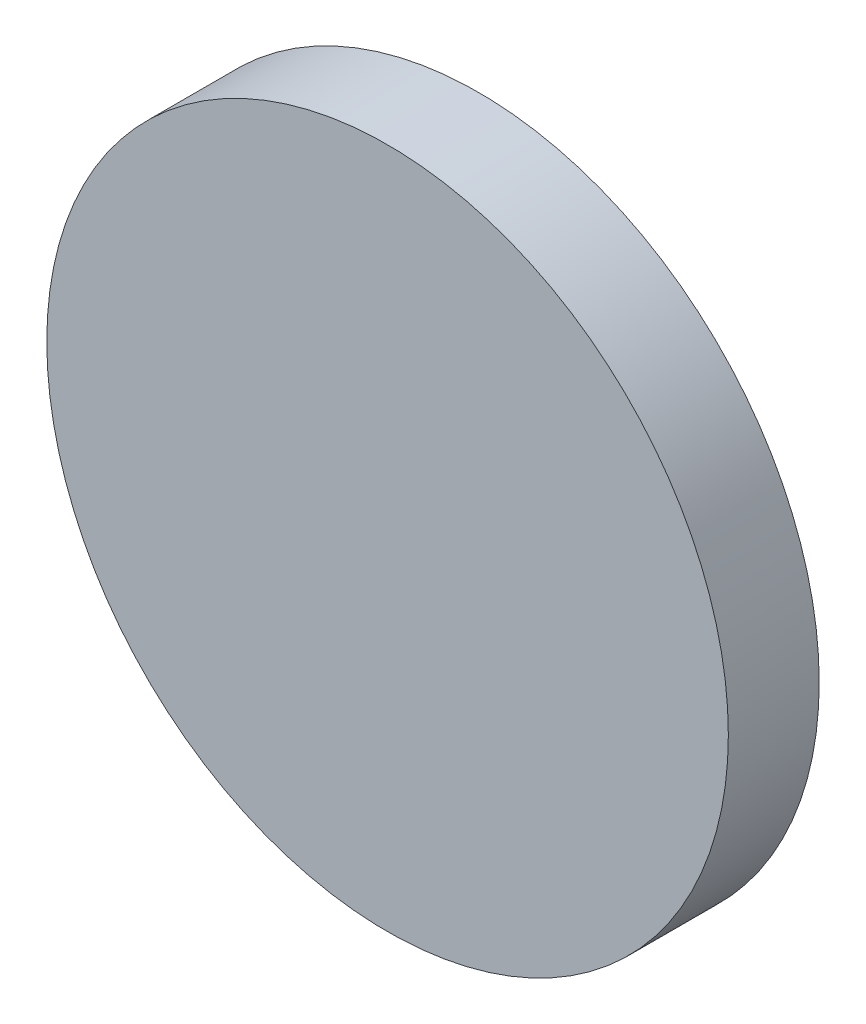
from build123d import *

# Parameters (mm, degrees)
SKETCH_1_R      = 15
EXTRUDE_1_DEPTH = 4


with BuildPart() as part:
    # 草图1 → 凸台-拉伸1 (new body)
    with BuildSketch(Plane.XY):
        Circle(SKETCH_1_R)
    extrude(amount=EXTRUDE_1_DEPTH)


solid = part.part
